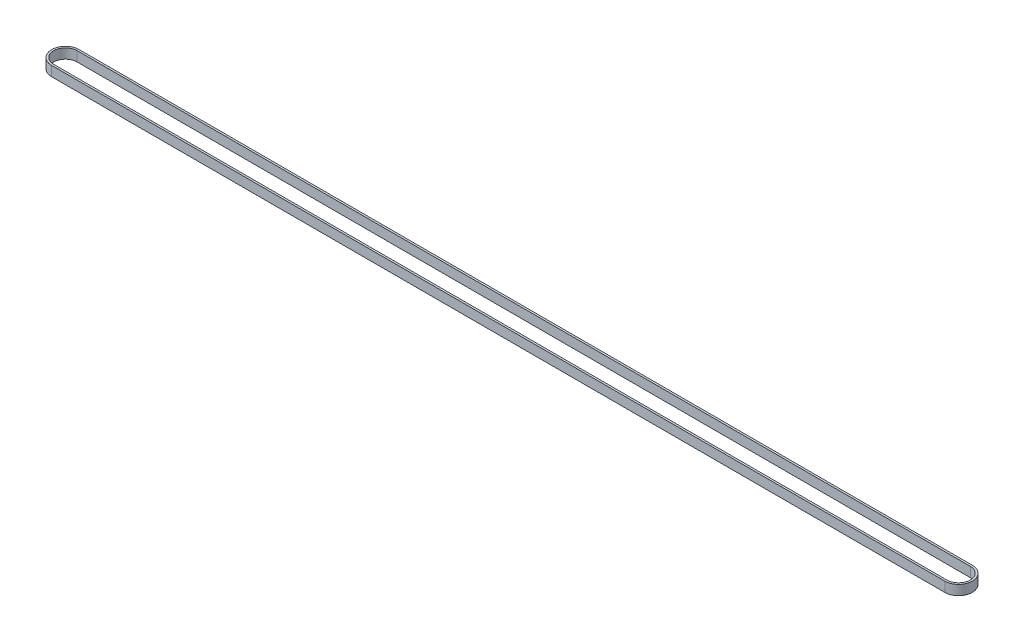
from build123d import *

# Parameters (mm, degrees)
BOSS_EXTRU_1_DEPTH = 5


with BuildPart() as part:
    # Esquisse1 → Boss.-Extru.1 (new body)
    with BuildSketch(Plane(origin=(0, -3570.450869545, 0), x_dir=(1, 0, 0), z_dir=(0, 1, 0))):
        with BuildLine():
            Line((-454.86, -7), (0, -7))
            ThreePointArc((0, -7), (7, 0), (0, 7))
            Line((0, 7), (-454.86, 7))
            ThreePointArc((-454.86, 7), (-461.86, 0), (-454.86, -7))
        make_face()
        with BuildLine():
            Line((-454.86, -6), (0, -6))
            ThreePointArc((0, -6), (6, 0), (0, 6))
            Line((0, 6), (-454.86, 6))
            ThreePointArc((-454.86, 6), (-460.86, 0), (-454.86, -6))
        make_face(mode=Mode.SUBTRACT)
    extrude(amount=BOSS_EXTRU_1_DEPTH)


solid = part.part
